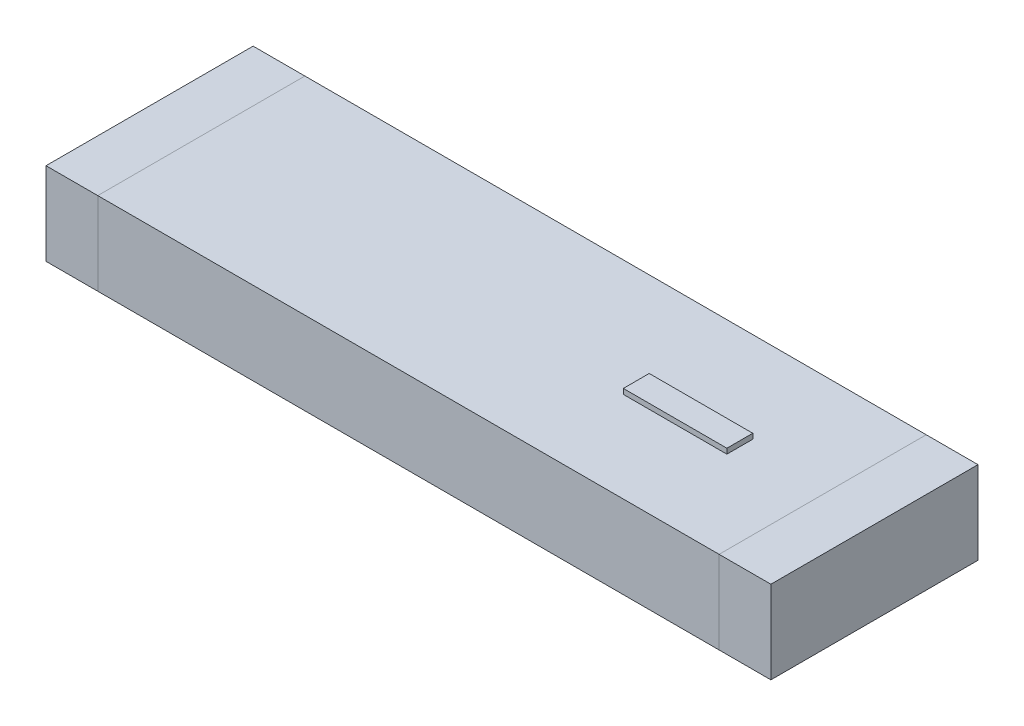
from build123d import *

# Parameters (mm, degrees)
SKETCH2_W             = 6
SKETCH2_H             = 2
BOSS_EXTRUDE1_DEPTH   = 0.8
SKETCH3_W             = 0.5
SKETCH3_H             = 2
BOSS_EXTRUDE2_DEPTH   = 0.8
BOSS_EXTRUDE2_2_DEPTH = 0.8
BOSS_EXTRUDE3_START   = 0.05
SKETCH4_W             = 1
SKETCH4_H             = 0.25
BOSS_EXTRUDE3_DEPTH   = 0.1


with BuildPart() as part:
    # Sketch2 → Boss-Extrude1 (new body)
    with BuildSketch(Plane(origin=(0, 0, 0), x_dir=(1, 0, 0), z_dir=(0, 1, 0))):
        Rectangle(SKETCH2_W, SKETCH2_H)
    extrude(amount=BOSS_EXTRUDE1_DEPTH)


with BuildPart() as body_2:
    # Sketch3 → Boss-Extrude2 (new body)
    with BuildSketch(Plane(origin=(0, 0, 0), x_dir=(1, 0, 0), z_dir=(0, 1, 0))):
        with Locations((-3.25, 0)):
            Rectangle(SKETCH3_W, SKETCH3_H)
    extrude(amount=BOSS_EXTRUDE2_DEPTH)


with BuildPart() as body_3:
    # Sketch3 → Boss-Extrude2 2 (new body)
    with BuildSketch(Plane(origin=(0, 0, 0), x_dir=(1, 0, 0), z_dir=(0, 1, 0))):
        with Locations((3.25, 0)):
            Rectangle(SKETCH3_W, SKETCH3_H)
    extrude(amount=BOSS_EXTRUDE2_2_DEPTH)


with BuildPart() as body_4:
    # Sketch4 → Boss-Extrude3 (new body)
    with BuildSketch(Plane(origin=(0, 0.8, 0), x_dir=(1, 0, 0), z_dir=(0, 1, 0)).offset(BOSS_EXTRUDE3_START)):
        with Locations((1.7, 0)):
            Rectangle(SKETCH4_W, SKETCH4_H)
    extrude(amount=-BOSS_EXTRUDE3_DEPTH)


solid = Compound([part.part, body_2.part, body_3.part, body_4.part])
